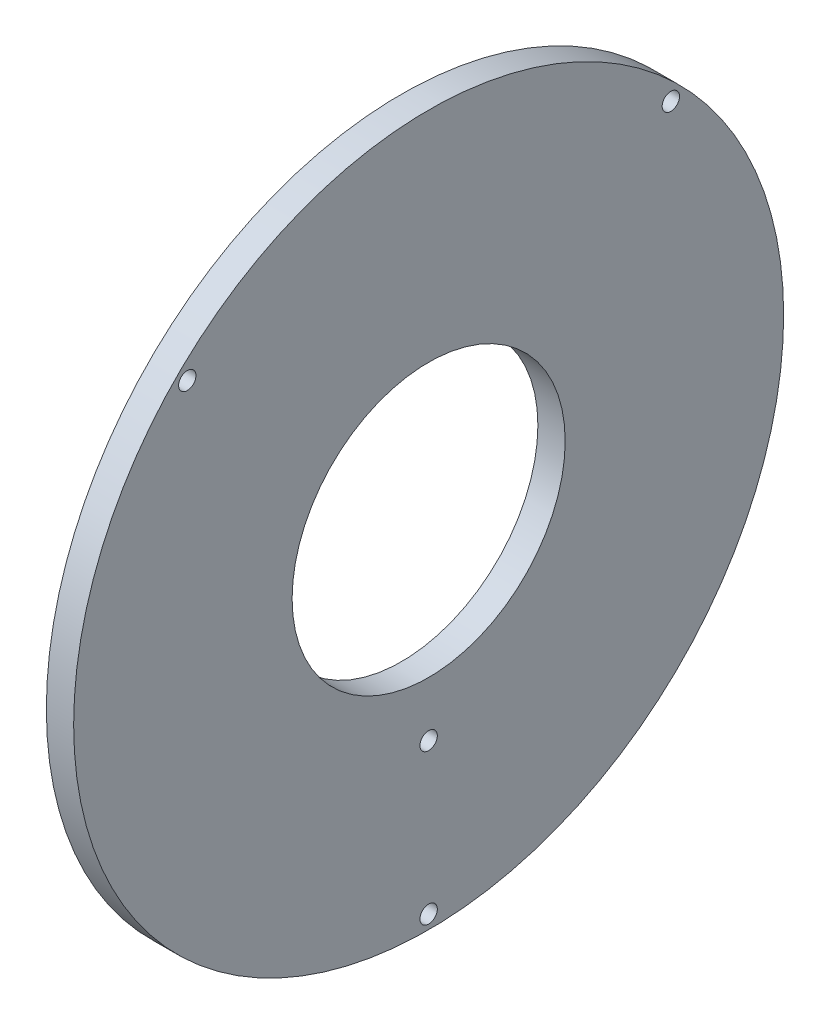
from build123d import *

# Parameters (mm, degrees)
SKETCH1_R                         = 260
BOSS_EXTRUDE1_DEPTH               = 20
SKETCH2_R                         = 100
CUT_EXTRUDE1_DEPTH                = 20
F_1_2_13_TAPPED_HOLE1_D           = 10.71626
F_1_2_13_TAPPED_HOLE1_DEPTH       = 70.4
F_1_2_13_TAPPED_HOLE1_CBORE_D     = 12.7
F_1_2_13_TAPPED_HOLE1_CBORE_DEPTH = 64.5
F_1_2_13_TAPPED_HOLE1_TIP         = 3.219489309


with BuildPart() as part:
    # Sketch1 → Boss-Extrude1 (new body)
    with BuildSketch(Plane(origin=(0, 0, 0), x_dir=(0, 0, -1), z_dir=(1, 0, 0))):
        Circle(SKETCH1_R)
    extrude(amount=BOSS_EXTRUDE1_DEPTH)

    # Sketch2 → Cut-Extrude1 (cut)
    with BuildSketch(Plane(origin=(20, 0, 0), x_dir=(0, 0, -1), z_dir=(1, 0, 0))):
        Circle(SKETCH2_R)
    extrude(amount=-CUT_EXTRUDE1_DEPTH, mode=Mode.SUBTRACT)

    # 1/2-13 Tapped Hole1
    with Locations(Plane(origin=(20, 176.776695297, -177.367627121), x_dir=(0, 0, 1), z_dir=(1, 0, 0))):
        with Locations((0, 0), (354.144322418, 0), (177.367627121, 426.776695297), (177.367627121, 316.776695297)):
            CounterBoreHole(F_1_2_13_TAPPED_HOLE1_D / 2, F_1_2_13_TAPPED_HOLE1_CBORE_D / 2, F_1_2_13_TAPPED_HOLE1_CBORE_DEPTH, depth=F_1_2_13_TAPPED_HOLE1_DEPTH)
            with Locations((0, 0, -(F_1_2_13_TAPPED_HOLE1_DEPTH + F_1_2_13_TAPPED_HOLE1_TIP / 2))):  # 118° drill point
                Cone(0, F_1_2_13_TAPPED_HOLE1_D / 2, F_1_2_13_TAPPED_HOLE1_TIP, mode=Mode.SUBTRACT)


solid = part.part
